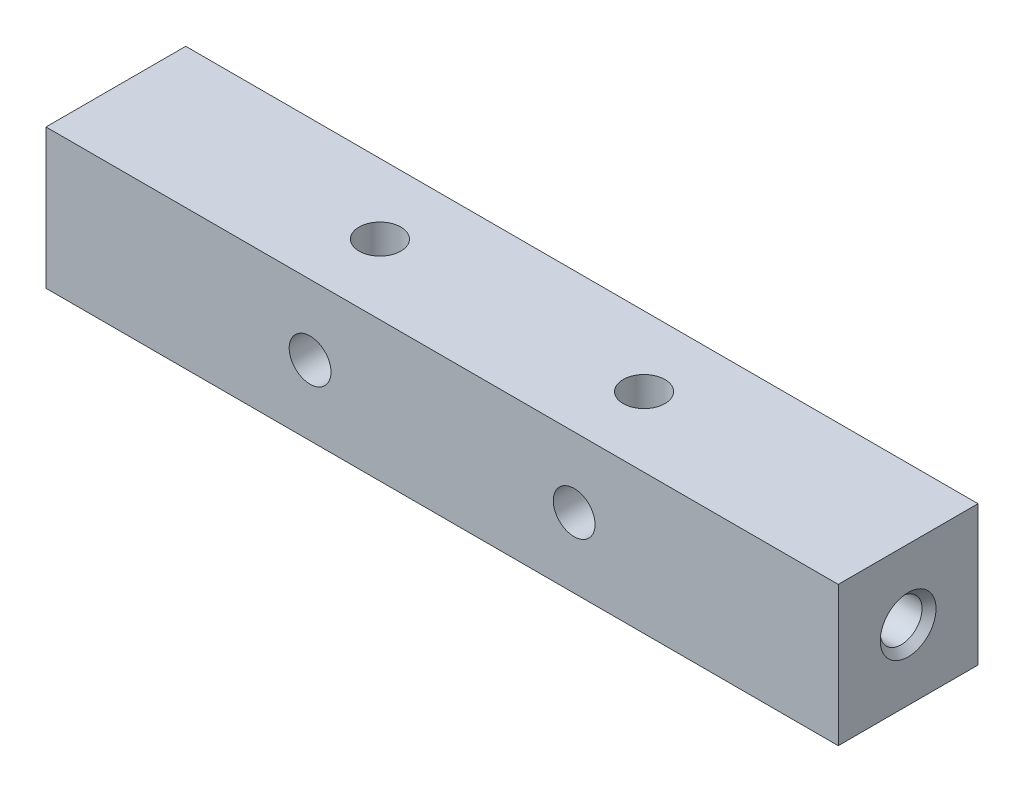
from build123d import *

# Parameters (mm, degrees)
SKETCH1_W                        = 12.7
SKETCH1_H                        = 12.7
BOSS_EXTRUDE1_DEPTH              = 72
F_10_24_TAPPED_HOLE1_D           = 3.7973
F_10_24_TAPPED_HOLE2_D           = 3.7973
M6X1_0_TAPPED_HOLE2_D            = 5
M6X1_0_TAPPED_HOLE2_DEPTH        = 20.32
M6X1_0_TAPPED_HOLE2_CSINK_D      = 6.05
M6X1_0_TAPPED_HOLE2_CSINK_ANGLE  = 90
M6X1_0_TAPPED_HOLE2_TIP          = 1.502151548
F_10_24_TAPPED_HOLE3_D           = 3.7973
F_10_24_TAPPED_HOLE3_DEPTH       = 20.574
F_10_24_TAPPED_HOLE3_CSINK_D     = 5.0673
F_10_24_TAPPED_HOLE3_CSINK_ANGLE = 90
F_10_24_TAPPED_HOLE3_TIP         = 1.140824014
LPATTERN1_COUNT                  = 2
LPATTERN1_PITCH                  = 24
LPATTERN2_COUNT                  = 2
LPATTERN2_PITCH                  = 24


with BuildPart() as part:
    # Sketch1 → Boss-Extrude1 (new body)
    with BuildSketch(Plane(origin=(0, 0, 0), x_dir=(0, 0, -1), z_dir=(1, 0, 0))):
        Rectangle(SKETCH1_W, SKETCH1_H)
    extrude(amount=BOSS_EXTRUDE1_DEPTH)

    # #10-24 Tapped Hole1 (through all)
    with Locations(Plane.XY.offset(6.35)):
        with Locations((24, 0)):
            f_10_24_tapped_hole1 = Hole(F_10_24_TAPPED_HOLE1_D / 2)

    # #10-24 Tapped Hole2 (through all)
    with Locations(Plane(origin=(0, 6.35, 0), x_dir=(1, 0, 0), z_dir=(0, 1, 0))):
        with Locations((24, 0)):
            f_10_24_tapped_hole2 = Hole(F_10_24_TAPPED_HOLE2_D / 2)

    # M6x1.0 Tapped Hole2
    with Locations(Plane.ZY):
        with Locations((0, 0)):
            CounterSinkHole(M6X1_0_TAPPED_HOLE2_D / 2, M6X1_0_TAPPED_HOLE2_CSINK_D / 2, depth=M6X1_0_TAPPED_HOLE2_DEPTH, counter_sink_angle=M6X1_0_TAPPED_HOLE2_CSINK_ANGLE)
            with Locations((0, 0, -(M6X1_0_TAPPED_HOLE2_DEPTH + M6X1_0_TAPPED_HOLE2_TIP / 2))):  # 118° drill point
                Cone(0, M6X1_0_TAPPED_HOLE2_D / 2, M6X1_0_TAPPED_HOLE2_TIP, mode=Mode.SUBTRACT)

    # #10-24 Tapped Hole3
    with Locations(Plane(origin=(72, 0, 0), x_dir=(0, 0, -1), z_dir=(1, 0, 0))):
        with Locations((0, 0)):
            CounterSinkHole(F_10_24_TAPPED_HOLE3_D / 2, F_10_24_TAPPED_HOLE3_CSINK_D / 2, depth=F_10_24_TAPPED_HOLE3_DEPTH, counter_sink_angle=F_10_24_TAPPED_HOLE3_CSINK_ANGLE)
            with Locations((0, 0, -(F_10_24_TAPPED_HOLE3_DEPTH + F_10_24_TAPPED_HOLE3_TIP / 2))):  # 118° drill point
                Cone(0, F_10_24_TAPPED_HOLE3_D / 2, F_10_24_TAPPED_HOLE3_TIP, mode=Mode.SUBTRACT)

    # LPattern1: #10-24 Tapped Hole1 ×2
    with Locations(*[(i * LPATTERN1_PITCH, 0, 0) for i in range(1, LPATTERN1_COUNT)]):
        add(f_10_24_tapped_hole1, mode=Mode.SUBTRACT)

    # LPattern2: #10-24 Tapped Hole2 ×2
    with Locations(*[(i * LPATTERN2_PITCH, 0, 0) for i in range(1, LPATTERN2_COUNT)]):
        add(f_10_24_tapped_hole2, mode=Mode.SUBTRACT)


solid = part.part
